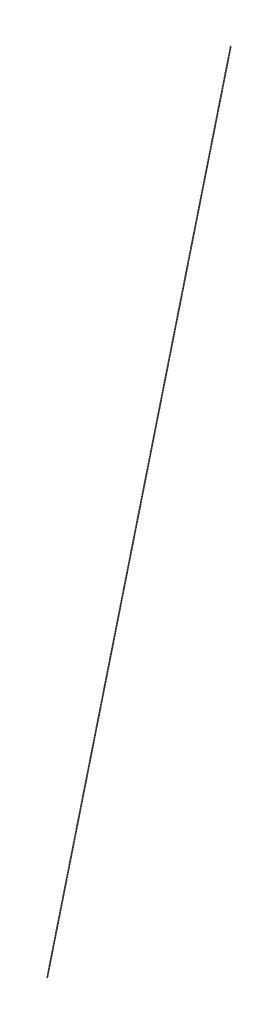
from build123d import *

# Parameters (mm, degrees)
SWEEP_1_PROFILE_R = 0.5


with BuildPart() as part:
    # 扫描1: sweep along a path in 草图2
    with BuildLine(Plane.XY) as sweep_1_path:
        Line((0, 0), (307.5, 1505))
    # 扫描1 profile (on start of the path) → 扫描1 (sweep)
    with BuildSketch(Plane(origin=(0, 0, 0), x_dir=(0.979758481, -0.200183211, 0), z_dir=(0.200183211, 0.979758481, 0))):
        Circle(SWEEP_1_PROFILE_R)
    sweep(path=sweep_1_path.line)


solid = part.part
